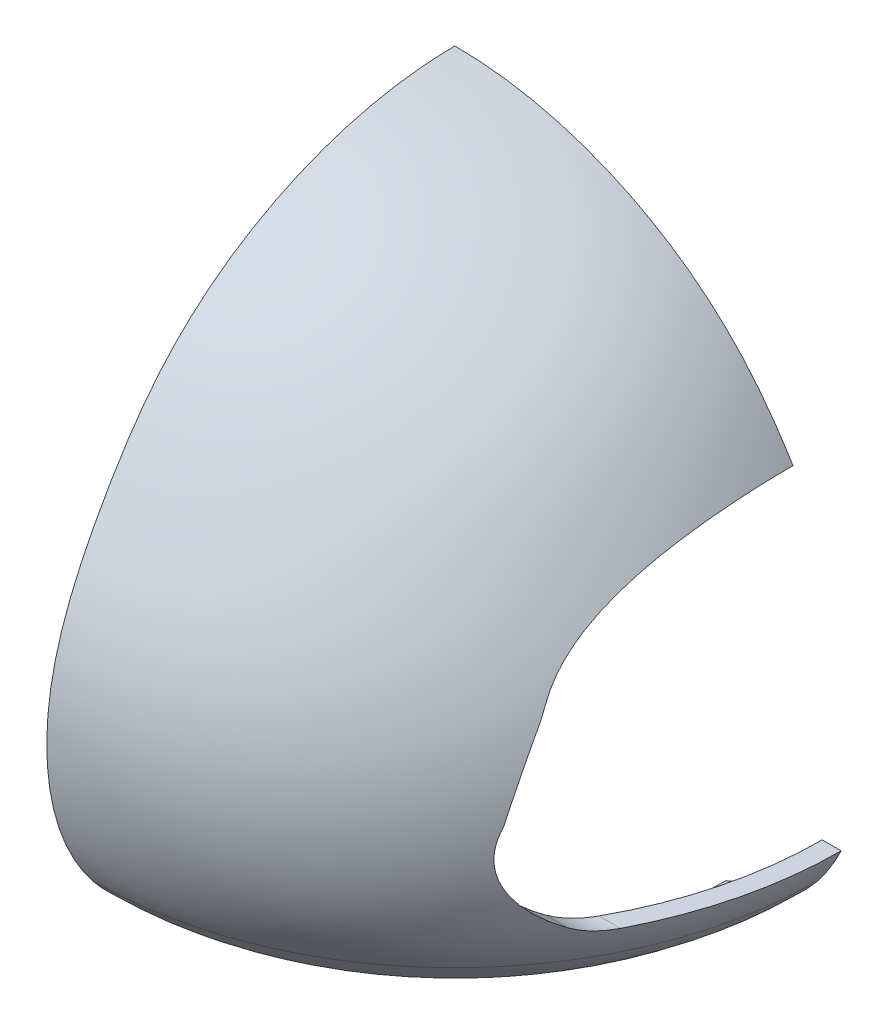
from build123d import *

# Parameters (mm, degrees)
SKETCH4_R           = 80.100145108
CUT_EXTRUDE2_DEPTH  = 20
CUT_EXTRUDE3_DEPTH  = 121.706010599
BOSS_EXTRUDE1_REACH = 54.085
SKETCH6_R           = 10
SKETCH7_W           = 348.912782296
SKETCH7_H           = 364.592796888
CUT_EXTRUDE4_DEPTH  = 159
SKETCH10_W          = 321.851433002
SKETCH10_H          = 336.106950371
CUT_EXTRUDE5_DEPTH  = 200


with BuildPart() as part:
    # Sketch3 → Revolve5 (revolve)
    with BuildSketch(Plane.XY):
        with BuildLine():
            Line((0.02453969, 157.084900749), (0.02453969, 152.084900749))
            add(Edge.make_bspline(
                [(-103.174583613, -2.6432e-05), (-114.760245555, 14.576189089), (-119.836740195, 49.27275863), (-101.45175109, 88.673946708), (-71.379831841, 134.479430747), (-29.75001244, 152.084900749), (0.02453969, 152.084900749)],
                knots=[0, 0, 0, 0, 0.250738493, 0.442513363, 0.587644713, 1, 1, 1, 1], degree=3))
            add(Edge.make_bspline(
                [(-103.174583613, -2.6432e-05), (-78.832759046, -30.064140021), (-33.458723298, -20.943389124), (0.02453969, -20.943389124)],
                knots=[0, 0, 0, 0, 1, 1, 1, 1], degree=3))
            Line((0.02453969, -20.943389124), (0.02453969, -25.943389124))
            add(Edge.make_bspline(
                [(0.02453969, -25.943389124), (-1.007843071, -25.943389124), (-3.05274325, -25.960735741), (-7.300680211, -26.054029266), (-12.774839269, -26.259816275), (-19.586870399, -26.581007249), (-28.911339242, -27.014332449), (-40.900445748, -27.386982651), (-55.443773123, -26.975342887), (-69.789912797, -25.08625158), (-81.278725906, -21.722461367), (-89.959801918, -17.60281584), (-96.13825684, -13.717797758), (-100.945853349, -9.752185194), (-104.534382709, -6.13029221), (-106.254478554, -4.141899361), (-107.07473695, -3.128814187)],
                knots=[-0.000194385, -0.000194385, -0.000194385, -0.000194385, 0.03106169, 0.062317764, 0.124829913, 0.187342062, 0.249854211, 0.37487851, 0.499902808, 0.624927106, 0.749951404, 0.812463553, 0.874975702, 0.937487851, 0.968743925, 1, 1, 1, 1], degree=3))
            add(Edge.make_bspline(
                [(-107.07473695, -3.128814187), (-107.861659129, -2.138767408), (-109.375579618, -0.100482773), (-112.095489807, 4.115600278), (-114.955951775, 9.644100323), (-117.55365357, 16.585319153), (-119.962688147, 26.134623726), (-121.103112226, 38.406473215), (-119.79356064, 53.088411426), (-116.089945574, 67.047457773), (-110.633897624, 80.23296506), (-104.034329909, 92.718986198), (-96.815301706, 104.751602155), (-88.512248671, 116.246845317), (-78.667704424, 126.697829164), (-67.464684594, 135.71357688), (-55.182594106, 143.280590712), (-42.054195525, 149.310974483), (-28.321126938, 153.731407172), (-14.204212291, 156.457352496), (-4.722534611, 157.084900749), (0.02453969, 157.084900749)],
                knots=[-0.000101258, -0.000101258, -0.000101258, -0.000101258, 0.015525324, 0.031151906, 0.06240507, 0.093658235, 0.124911399, 0.187417728, 0.249924056, 0.312430385, 0.374936714, 0.437443042, 0.499949371, 0.562455699, 0.624962028, 0.687468357, 0.749974685, 0.812481014, 0.874987343, 0.937493671, 1, 1, 1, 1], degree=3))
        make_face()
    revolve(axis=Axis((0.02453969, 171.610282588, 0), (0, -1, 0)))

    # Sketch4 → Cut-Extrude2 (cut)
    with BuildSketch(Plane(origin=(0, -30, 0), x_dir=(1, 0, 0), z_dir=(0, 1, 0))):
        Circle(SKETCH4_R)
    extrude(amount=CUT_EXTRUDE2_DEPTH, mode=Mode.SUBTRACT)

    # Sketch5 → Cut-Extrude3 (cut, through all)
    with BuildSketch(Plane(origin=(0, 0, 0), x_dir=(0, 0, -1), z_dir=(1, 0, 0))):
        with BuildLine():
            Line((-52.476481645, 8.136577936), (52.476481645, 8.136577936))
            ThreePointArc((52.476481645, 8.136577936), (58.138069368, 8.954648303), (63.336499377, 11.341935492))
            add(Edge.make_bspline(
                [(63.336499377, 11.341935492), (82.622361185, 23.812864951), (78.746201445, 39.317958114)],
                knots=[5.637022825, 5.637022825, 5.637022825, 6.404500867, 6.404500867, 6.404500867], degree=2, weights=[1, 0.927271268, 1]))
            ThreePointArc((78.746201445, 39.317958114), (77.929706658, 42.769255575), (77.20089719, 46.240127895))
            add(Edge.make_bspline(
                [(70.494135614, 63.047069033), (72.356334923, 60.10156835), (75.045149162, 54.673263207), (76.692738831, 48.822390655), (77.20089719, 46.240127895)],
                knots=[0.168181527, 0.168181527, 0.168181527, 0.168181527, 0.552818848, 0.845617793, 0.845617793, 0.845617793, 0.845617793], degree=3))
            ThreePointArc((70.494135614, 63.047069033), (68.293855497, 66.646255249), (66.203011989, 70.31009851))
            add(Edge.make_bspline(
                [(66.203011989, 70.31009851), (-4.427969211, 198.528374497), (-67.022107814, 68.723719713)],
                knots=[0.328274459, 0.328274459, 0.328274459, 2.851830568, 2.851830568, 2.851830568], degree=2, weights=[1, 0.304123557, 1]))
            ThreePointArc((-67.022107814, 68.723719713), (-68.159373057, 66.423614108), (-69.341813393, 64.146402461))
            add(Edge.make_bspline(
                [(-69.341813393, 64.146402461), (-73.061653072, 57.152172395), (-75.898874077, 49.79082496), (-77.836559233, 42.105665134)],
                knots=[0.114274397, 0.114274397, 0.114274397, 0.114274397, 1, 1, 1, 1], degree=3))
            add(Edge.make_bspline(
                [(-77.836559233, 42.105665134), (-84.680776254, 25.143909909), (-63.336499377, 11.341935492)],
                knots=[2.947295522, 2.947295522, 2.947295522, 3.787755136, 3.787755136, 3.787755136], degree=2, weights=[1, 0.91299521, 1]))
            ThreePointArc((-63.336499377, 11.341935492), (-58.138069368, 8.954648303), (-52.476481645, 8.136577936))
        make_face()
    extrude(amount=CUT_EXTRUDE3_DEPTH, mode=Mode.SUBTRACT)

    # Sketch6 → Boss-Extrude1 (add, up to next)
    with BuildSketch(Plane(origin=(0, 105, 0), x_dir=(1, 0, 0), z_dir=(0, 1, 0)), mode=Mode.PRIVATE) as boss_extrude1_sk1:
        Circle(SKETCH6_R)
    boss_extrude1_tool1 = extrude(boss_extrude1_sk1.sketch, amount=BOSS_EXTRUDE1_REACH, mode=Mode.PRIVATE) - part.part
    add(boss_extrude1_tool1.solids().sort_by_distance((0, 105, 0))[0])

    # Sketch7 → Cut-Extrude4 (cut)
    with BuildSketch(Plane.XY):
        Rectangle(SKETCH7_W, SKETCH7_H)
    extrude(amount=-CUT_EXTRUDE4_DEPTH, mode=Mode.SUBTRACT)

    # Sketch10 → Cut-Extrude5 (cut)
    with BuildSketch(Plane(origin=(0, 0, 0), x_dir=(0, 0, -1), z_dir=(1, 0, 0))):
        with Locations((0, -2.6432e-05)):
            Rectangle(SKETCH10_W, SKETCH10_H)
    extrude(amount=-CUT_EXTRUDE5_DEPTH, mode=Mode.SUBTRACT)


solid = part.part
